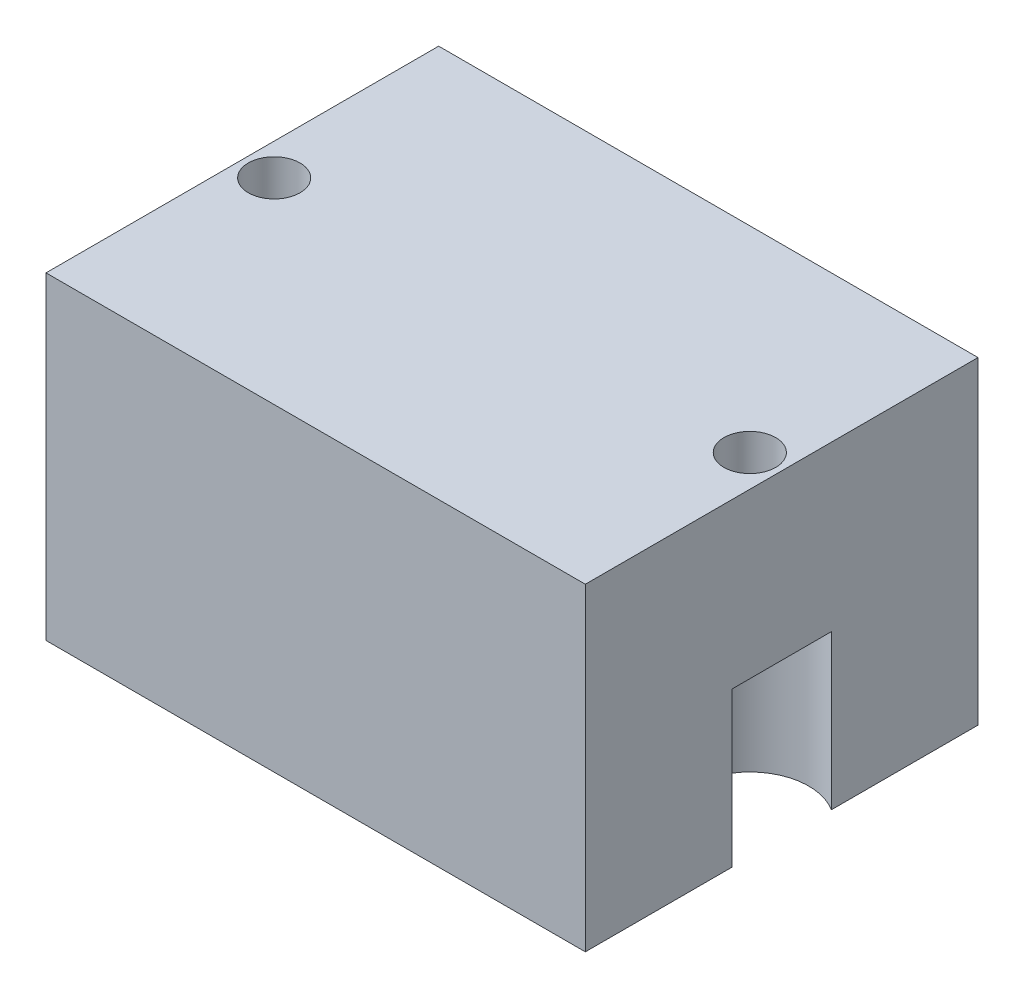
from build123d import *

# Parameters (mm, degrees)
SKETCH1_W                                           = 25.41
SKETCH1_H                                           = 18.5
BOSS_EXTRUDE1_DEPTH                                 = 15
F_2_56_TAPPED_HOLE1_D                               = 1.778
F_2_56_TAPPED_HOLE1_DEPTH                           = 7.46583491
F_2_56_TAPPED_HOLE1_TIP                             = 0.53416509
SKETCH5_R                                           = 3
CUT_EXTRUDE1_DEPTH                                  = 3
CBORE_FOR_2_BINDING_HEAD_MACHINE_SCREW1_D           = 2.4384
CBORE_FOR_2_BINDING_HEAD_MACHINE_SCREW1_CBORE_D     = 5.55752
CBORE_FOR_2_BINDING_HEAD_MACHINE_SCREW1_CBORE_DEPTH = 7.269988


with BuildPart() as part:
    # Sketch1 → Boss-Extrude1 (new body)
    with BuildSketch(Plane(origin=(0, 0, 0), x_dir=(1, 0, 0), z_dir=(0, 1, 0))):
        with Locations((12.705, 9.25)):
            Rectangle(SKETCH1_W, SKETCH1_H)
    extrude(amount=BOSS_EXTRUDE1_DEPTH)

    # #2-56 Tapped Hole1
    with Locations(Plane(origin=(0, 0, 0), x_dir=(-1, 0, 0), z_dir=(0, -1, 0))):
        with Locations((-23.91, 17), (-23.91, 1.5), (-1.5, 1.5), (-1.5, 17)):
            Hole(F_2_56_TAPPED_HOLE1_D / 2, depth=F_2_56_TAPPED_HOLE1_DEPTH)
            with Locations((0, 0, -(F_2_56_TAPPED_HOLE1_DEPTH + F_2_56_TAPPED_HOLE1_TIP / 2))):  # 118° drill point
                Cone(0, F_2_56_TAPPED_HOLE1_D / 2, F_2_56_TAPPED_HOLE1_TIP, mode=Mode.SUBTRACT)

    # Sketch5 → Cut-Extrude1 (cut)
    with BuildSketch(Plane.XZ):
        with Locations((12.705, -9.25)):
            Circle(SKETCH5_R)
    extrude(amount=-CUT_EXTRUDE1_DEPTH, mode=Mode.SUBTRACT)

    # CBORE for #2 Binding Head Machine Screw1 (through all)
    with Locations(Plane(origin=(0, 0, 0), x_dir=(-1, 0, 0), z_dir=(0, -1, 0))):
        with Locations((-23.91, 9.25), (-1.5, 9.25)):
            CounterBoreHole(CBORE_FOR_2_BINDING_HEAD_MACHINE_SCREW1_D / 2, CBORE_FOR_2_BINDING_HEAD_MACHINE_SCREW1_CBORE_D / 2, CBORE_FOR_2_BINDING_HEAD_MACHINE_SCREW1_CBORE_DEPTH)


solid = part.part
